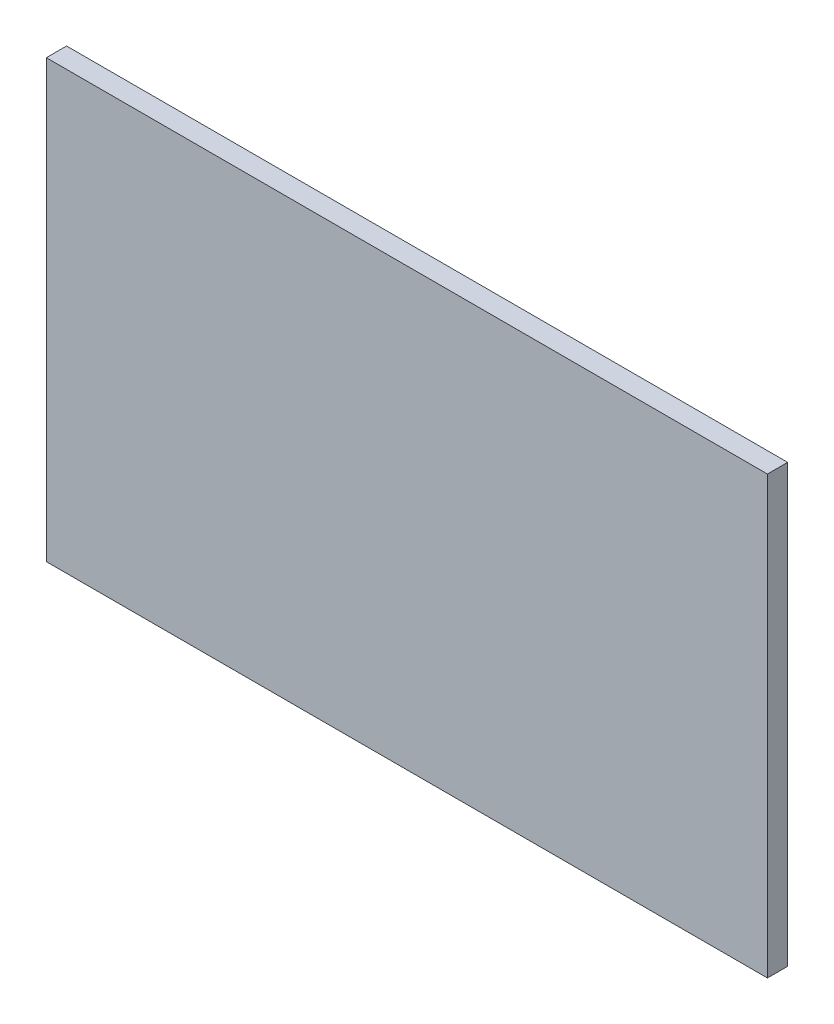
from build123d import *

# Parameters (mm, degrees)
SKETCH1_W           = 57
SKETCH1_H           = 34.5
BOSS_EXTRUDE1_DEPTH = 1.6


with BuildPart() as part:
    # Sketch1 → Boss-Extrude1 (new body)
    with BuildSketch(Plane.XY):
        with Locations((-11.494856457, 38.244856457)):
            Rectangle(SKETCH1_W, SKETCH1_H)
    extrude(amount=BOSS_EXTRUDE1_DEPTH)


solid = part.part
